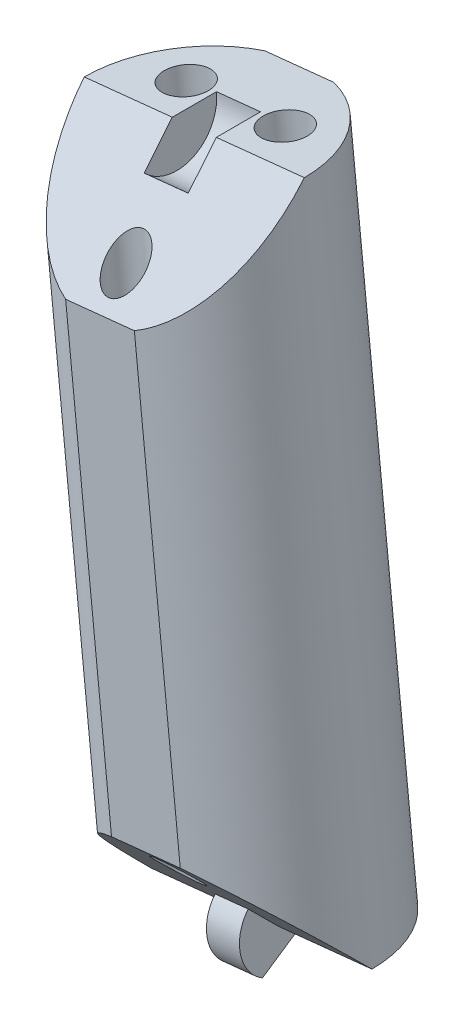
from build123d import *

# Parameters (mm, degrees)
SKETCH3_R               = 8
BOSS_EXTRUDE1_DEPTH     = 47.368421053
CUT_EXTRUDE1_DEPTH      = 13.860013886
CUT_EXTRUDE1_DEPTH_BACK = 13.860013886
BOSS_EXTRUDE2_DEPTH     = 1.2
CUT_EXTRUDE2_DEPTH      = 1.6
SKETCH8_R               = 1.4
SKETCH8_R_2             = 1.6
CUT_EXTRUDE3_DEPTH      = 2.64160469
CUT_EXTRUDE3_DEPTH_BACK = 51.711414178
CUT_EXTRUDE4_DEPTH      = 51.711414178


with BuildPart() as part:
    # Sketch3 → Boss-Extrude1 (new body)
    with BuildSketch(Plane(origin=(-20.344467381, 196.178792599, 0), x_dir=(-0.994665758, -0.103150523, 0), z_dir=(0.103150523, -0.994665758, 0))):
        with Locations((-10.431405186, 0)):
            Circle(SKETCH3_R)
    extrude(amount=BOSS_EXTRUDE1_DEPTH)

    # Sketch4 → Cut-Extrude1 (cut, two sides)
    with BuildSketch(Plane(origin=(10.375761543, 1.076004901, 0), x_dir=(0.103150523, -0.994665758, 0), z_dir=(-0.994665758, -0.103150523, 0))) as cut_extrude1_sk:
        Polygon((-197.230869842, 0), (-189.230869842, 8), (-197.230869842, 8), align=None)
        Polygon((-157.862448789, 8), (-149.862448789, 8), (-149.862448789, 0), align=None)
    extrude(amount=CUT_EXTRUDE1_DEPTH, mode=Mode.SUBTRACT)
    extrude(cut_extrude1_sk.sketch, amount=-CUT_EXTRUDE1_DEPTH_BACK, mode=Mode.SUBTRACT)

    # Sketch5 → Boss-Extrude2 (add, symmetric)
    with BuildSketch(Plane(origin=(10.375761543, 1.076004901, 0), x_dir=(0.103150523, -0.994665758, 0), z_dir=(-0.994665758, -0.103150523, 0))):
        with BuildLine():
            Line((-149.862448789, -2.8), (-147.437577659, 1.4))
            ThreePointArc((-147.437577659, 1.4), (-149.496975451, 2.776045612), (-151.842347777, 1.979898987))
            Line((-151.842347777, 1.979898987), (-149.862448789, 0))
            Line((-149.862448789, 0), (-149.862448789, -2.8))
        make_face()
    extrude(amount=BOSS_EXTRUDE2_DEPTH, both=True)

    # Sketch7 → Cut-Extrude2 (cut, symmetric)
    with BuildSketch(Plane(origin=(10.375761543, 1.076004901, 0), x_dir=(0.103150523, -0.994665758, 0), z_dir=(-0.994665758, -0.103150523, 0))):
        with BuildLine():
            Line((-194.968128142, 2.2627417), (-197.230869842, 0))
            Line((-197.230869842, 0), (-197.230869842, -3.2))
            ThreePointArc((-197.230869842, -3.2), (-194.274455338, -1.224586984), (-194.968128142, 2.2627417))
        make_face()
    extrude(amount=CUT_EXTRUDE2_DEPTH, both=True, mode=Mode.SUBTRACT)

    # Sketch8 → Cut-Extrude3 (cut, two sides)
    with BuildSketch(Plane(origin=(-20.344467381, 196.178792599, 0), x_dir=(0.994665758, 0.103150523, 0), z_dir=(-0.103150523, 0.994665758, 0))) as cut_extrude3_sk:
        with Locations((10.431405186, -5.5)):
            Circle(SKETCH8_R)
        with Locations((6.831405186, 3)):
            Circle(SKETCH8_R_2)
        with Locations((14.031405186, 3)):
            Circle(SKETCH8_R_2)
    extrude(amount=CUT_EXTRUDE3_DEPTH, mode=Mode.SUBTRACT)
    extrude(cut_extrude3_sk.sketch, amount=-CUT_EXTRUDE3_DEPTH_BACK, mode=Mode.SUBTRACT)

    # Sketch9 → Cut-Extrude4 (cut, through all)
    with BuildSketch(Plane(origin=(-20.344467381, 196.178792599, 0), x_dir=(0.994665758, 0.103150523, 0), z_dir=(-0.103150523, 0.994665758, 0))):
        with BuildLine():
            Line((7.933405986, 7.6), (12.929404385, 7.6))
            ThreePointArc((12.929404385, 7.6), (10.431405186, 8), (7.933405986, 7.6))
        make_face()
        with BuildLine():
            Line((7.933405986, -7.6), (12.929404385, -7.6))
            ThreePointArc((12.929404385, -7.6), (10.431405186, -8), (7.933405986, -7.6))
        make_face()
    extrude(amount=-CUT_EXTRUDE4_DEPTH, mode=Mode.SUBTRACT)


solid = part.part
